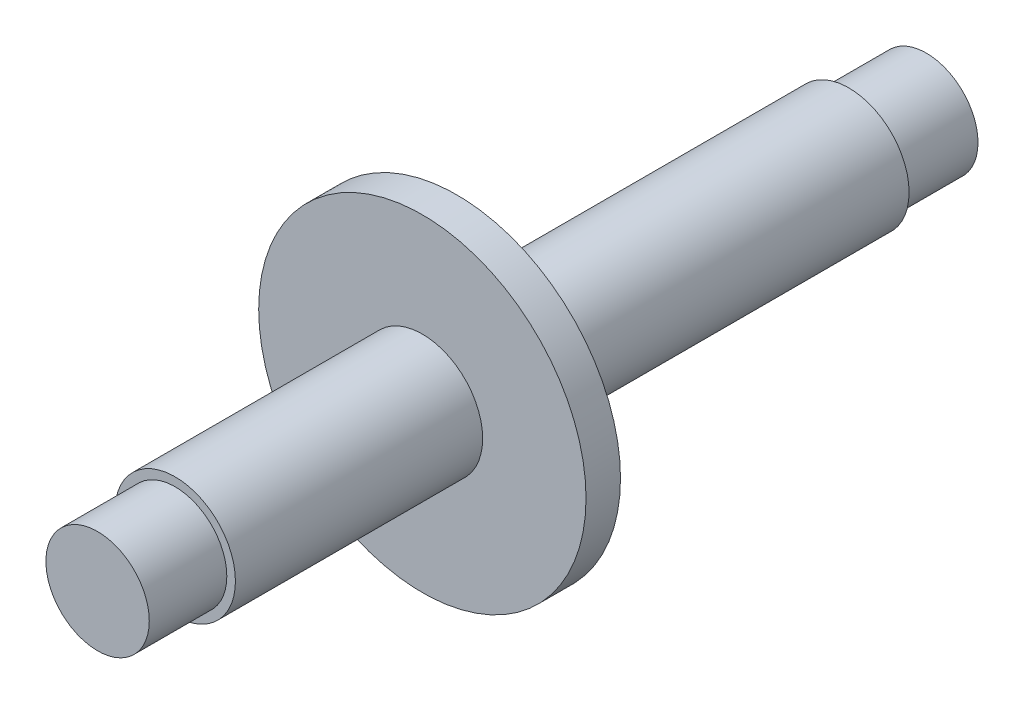
from build123d import *

# Parameters (mm, degrees)
CROQUIS1_R              = 3
SALIENTE_EXTRUIR1_DEPTH = 4.5
CROQUIS2_R              = 3.5
SALIENTE_EXTRUIR2_DEPTH = 22.75
CROQUIS3_R              = 9.5
SALIENTE_EXTRUIR3_DEPTH = 2
CROQUIS4_R              = 3.5
SALIENTE_EXTRUIR4_DEPTH = 14.35
CROQUIS5_R              = 3
SALIENTE_EXTRUIR5_DEPTH = 4.5


with BuildPart() as part:
    # Croquis1 → Saliente-Extruir1 (new body)
    with BuildSketch(Plane.XY):
        Circle(CROQUIS1_R)
    extrude(amount=SALIENTE_EXTRUIR1_DEPTH)

    # Croquis2 → Saliente-Extruir2 (add)
    with BuildSketch(Plane.XY.offset(4.5)):
        Circle(CROQUIS2_R)
    extrude(amount=SALIENTE_EXTRUIR2_DEPTH)

    # Croquis3 → Saliente-Extruir3 (add)
    with BuildSketch(Plane.XY.offset(27.25)):
        Circle(CROQUIS3_R)
    extrude(amount=SALIENTE_EXTRUIR3_DEPTH)

    # Croquis4 → Saliente-Extruir4 (add)
    with BuildSketch(Plane.XY.offset(29.25)):
        Circle(CROQUIS4_R)
    extrude(amount=SALIENTE_EXTRUIR4_DEPTH)

    # Croquis5 → Saliente-Extruir5 (add)
    with BuildSketch(Plane.XY.offset(43.6)):
        Circle(CROQUIS5_R)
    extrude(amount=SALIENTE_EXTRUIR5_DEPTH)


solid = part.part
